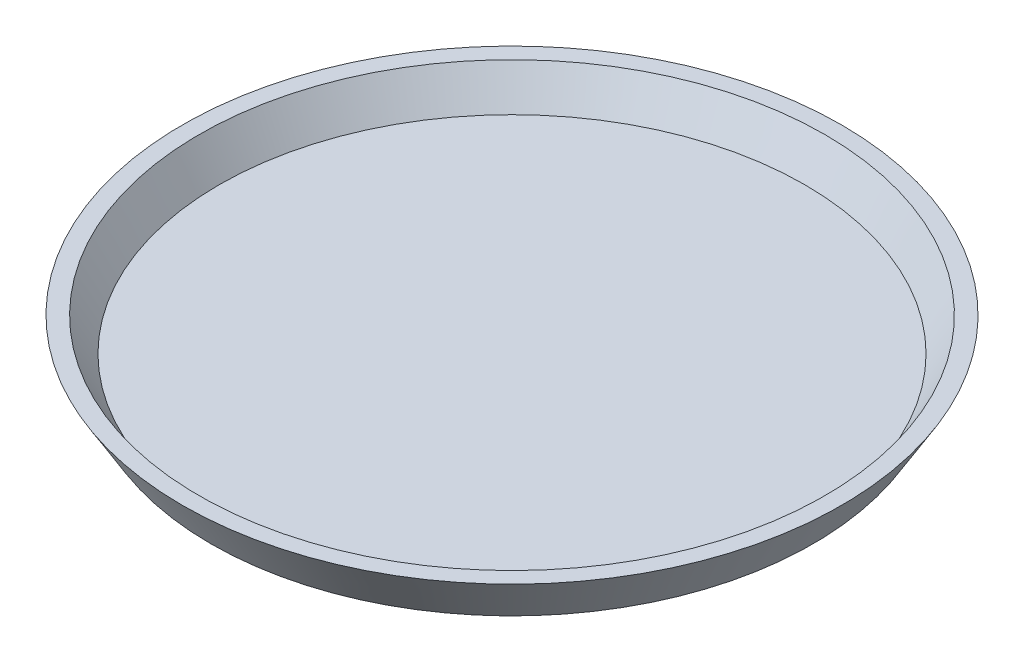
from build123d import *


with BuildPart() as part:
    # Sketch1 → Revolve1 (revolve)
    with BuildSketch(Plane.XY):
        Polygon((0, 0), (63, 0), (69, 10), (65.501428863, 10), (61.301428863, 3), (0, 3), align=None)
    revolve(axis=Axis((0, 0, 0), (0, 1, 0)))


solid = part.part
